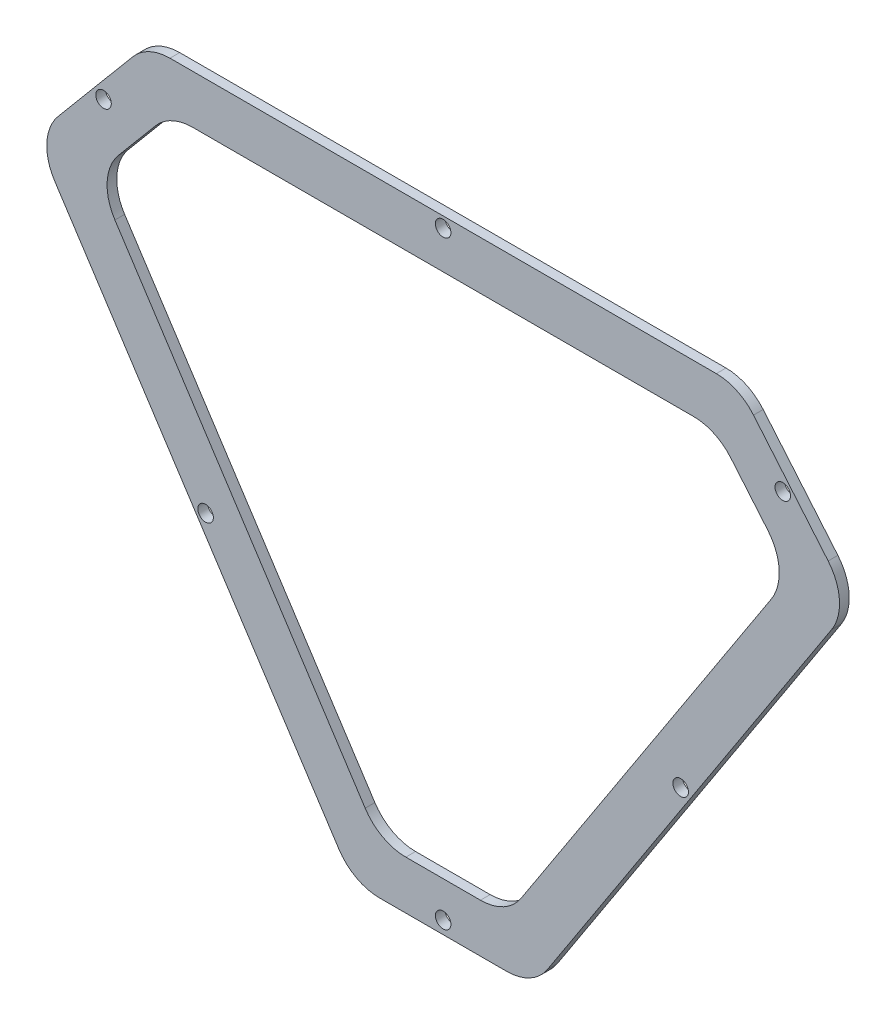
from build123d import *

# Parameters (mm, degrees)
BOSS_EXTRU_1_DEPTH      = 2
CONG_1_R                = 10
ENL_V_MAT_EXTRU_1_DEPTH = 2
CONG_2_R                = 10
ESQUISSE3_R             = 1.6
ENL_V_MAT_EXTRU_2_DEPTH = 10


with BuildPart() as part:
    # Esquisse1 → Boss.-Extru.1 (new body)
    with BuildSketch(Plane.XY):
        Polygon((-40.879571388, 34.615718895), (81.042798068, 34.615718895), (104.193503713, 7.025782272), (38.617977526, -93.674532757), (1.545249154, -93.674532757), (-64.030277033, 7.025782272), align=None)
    extrude(amount=BOSS_EXTRU_1_DEPTH)

    # Congé1
    cong_1_edges = [part.edges().sort_by_distance(p)[0] for p in [
        (-40.879571388, 34.615718895, 1),
        (81.042798068, 34.615718895, 1),
        (104.193503713, 7.025782272, 1),
        (38.617977526, -93.674532757, 1),
        (1.545249154, -93.674532757, 1),
        (-64.030277033, 7.025782272, 1),
    ]]
    fillet(cong_1_edges, radius=CONG_1_R)

    # Esquisse2 → Enlèv. mat.-Extru.1 (cut)
    with BuildSketch(Plane.XY.offset(2)):
        Polygon((-36.216494806, 24.615718895), (-51.607204261, 6.27378561), (6.96667711, -83.674532757), (33.19654957, -83.674532757), (91.770430941, 6.27378561), (76.379721487, 24.615718895), align=None)
    extrude(amount=-ENL_V_MAT_EXTRU_1_DEPTH, mode=Mode.SUBTRACT)

    # Congé2
    cong_2_edges = [part.edges().sort_by_distance(p)[0] for p in [
        (-36.216494806, 24.615718895, 1),
        (76.379721487, 24.615718895, 1),
        (91.770430941, 6.27378561, 1),
        (33.19654957, -83.674532757, 1),
        (6.96667711, -83.674532757, 1),
        (-51.607204261, 6.27378561, 1),
    ]]
    fillet(cong_2_edges, radius=CONG_2_R)

    # Esquisse3 → Enlèv. mat.-Extru.2 (cut)
    with BuildSketch(Plane.XY.offset(2)):
        with Locations((20.08161334, -91.058073416)):
            Circle(ESQUISSE3_R)
        with Locations((-28.872824595, -42.931783887)):
            Circle(ESQUISSE3_R)
        with Locations((20.08161334, 32.415718895)):
            Circle(ESQUISSE3_R)
        with Locations((90.076701777, 20.426939275)):
            Circle(ESQUISSE3_R)
        with Locations((69.036051275, -42.931783887)):
            Circle(ESQUISSE3_R)
        with Locations((-49.913475097, 20.426939275)):
            Circle(ESQUISSE3_R)
    extrude(amount=-ENL_V_MAT_EXTRU_2_DEPTH, mode=Mode.SUBTRACT)


solid = part.part
